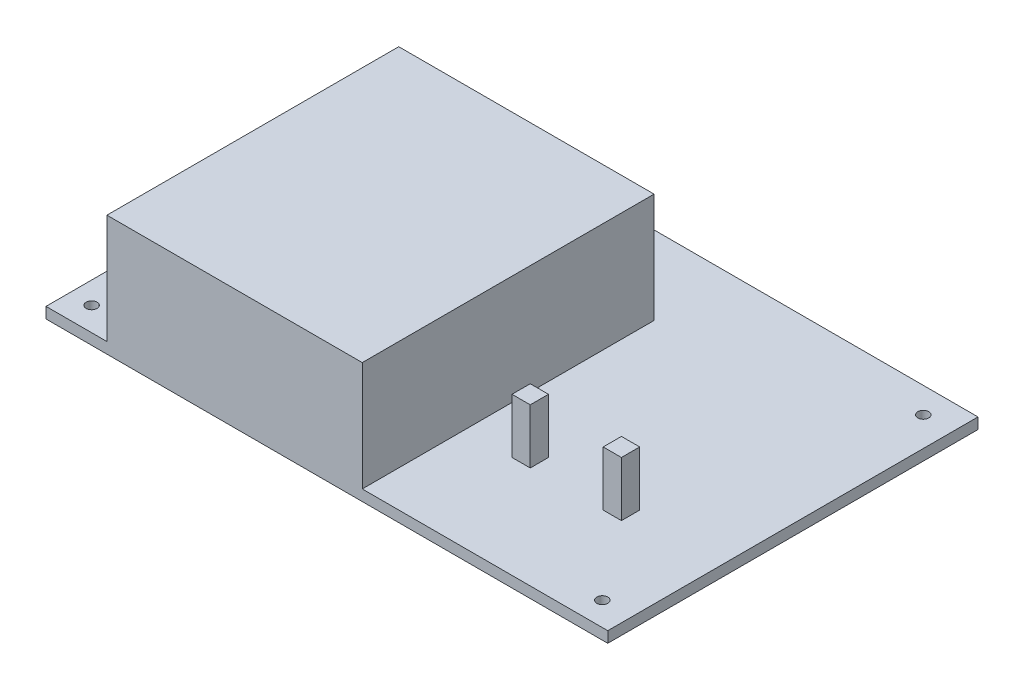
from build123d import *

# Parameters (mm, degrees)
ESQUISSE1_W             = 154
ESQUISSE1_H             = 101.5
BOSS_EXTRU_1_DEPTH      = 3
ESQUISSE2_R             = 1.5
ENL_V_MAT_EXTRU_1_DEPTH = 3
ESQUISSE3_W             = 70
ESQUISSE3_H             = 80
BOSS_EXTRU_2_DEPTH      = 30
ESQUISSE4_W             = 5
ESQUISSE4_H             = 5
BOSS_EXTRU_3_DEPTH      = 15
ESQUISSE5_R             = 5
ENL_V_MAT_EXTRU_2_DEPTH = 1


with BuildPart() as part:
    # Esquisse1 → Boss.-Extru.1 (new body)
    with BuildSketch(Plane(origin=(0, 0, 0), x_dir=(1, 0, 0), z_dir=(0, 1, 0))):
        Rectangle(ESQUISSE1_W, ESQUISSE1_H)
    extrude(amount=BOSS_EXTRU_1_DEPTH)

    # Esquisse2 → Enlèv. mat.-Extru.1 (cut)
    with BuildSketch(Plane(origin=(0, 3, 0), x_dir=(1, 0, 0), z_dir=(0, 1, 0))):
        with Locations((-71, 43.75)):
            Circle(ESQUISSE2_R)
        with Locations((69, 43.75)):
            Circle(ESQUISSE2_R)
        with Locations((-71, -44.25)):
            Circle(ESQUISSE2_R)
        with Locations((69, -44.25)):
            Circle(ESQUISSE2_R)
    extrude(amount=-ENL_V_MAT_EXTRU_1_DEPTH, mode=Mode.SUBTRACT)

    # Esquisse3 → Boss.-Extru.2 (add)
    with BuildSketch(Plane(origin=(0, 3, 0), x_dir=(1, 0, 0), z_dir=(0, 1, 0))):
        with Locations((-25.3, -10.75)):
            Rectangle(ESQUISSE3_W, ESQUISSE3_H)
    extrude(amount=BOSS_EXTRU_2_DEPTH)

    # Esquisse4 → Boss.-Extru.3 (add)
    with BuildSketch(Plane(origin=(0, 3, 0), x_dir=(1, 0, 0), z_dir=(0, 1, 0))):
        with Locations((25.25, -20.25)):
            Rectangle(ESQUISSE4_W, ESQUISSE4_H)
        with Locations((50.25, -20.25)):
            Rectangle(ESQUISSE4_W, ESQUISSE4_H)
    extrude(amount=BOSS_EXTRU_3_DEPTH)

    # Esquisse5 → Enlèv. mat.-Extru.2 (cut)
    with BuildSketch(Plane.XZ):
        Circle(ESQUISSE5_R)
    extrude(amount=-ENL_V_MAT_EXTRU_2_DEPTH, mode=Mode.SUBTRACT)


solid = part.part
